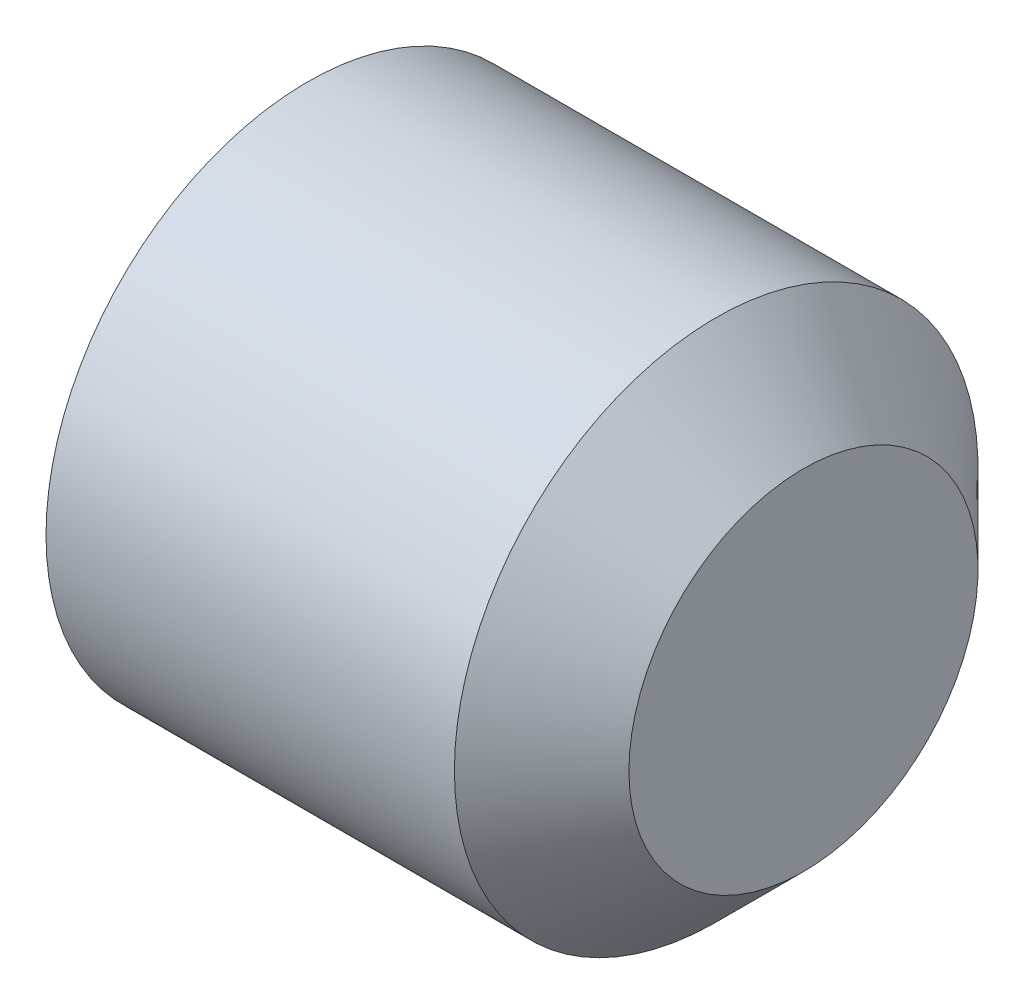
from build123d import *

# Parameters (mm, degrees)
CUT_EXTRUDE_1_DEPTH = 2
CHAMFER_1_SIZE      = 0.5545
CHAMFER_1_SIZE2     = 0.320140724


with BuildPart() as part:
    # Эскиз1 → Повернуть1 (revolve)
    with BuildSketch(Plane(origin=(0, 0, 0), x_dir=(-1, 0, 0), z_dir=(0, 0, -1))):
        Polygon((-6, 2), (-6, 0), (0, 0), (0, 3), (-5, 3), align=None)
    revolve(axis=Axis((6, 0, 0), (-1, 0, 0)))

    # Эскиз2 → Вырез-Вытянуть1 (cut)
    with BuildSketch(Plane.ZY):
        Polygon((1.732050808, 0), (0.866025404, 1.5), (-0.866025404, 1.5), (-1.732050808, 0), (-0.866025404, -1.5), (0.866025404, -1.5), align=None)
    extrude(amount=-CUT_EXTRUDE_1_DEPTH, mode=Mode.SUBTRACT)

    # Фаска1
    chamfer_1_edges = [part.edges().sort_by_distance(p)[0] for p in [
        (0, -3, 0),
    ]]
    chamfer_1_side = [part.faces().sort_by_distance(p)[0] for p in [
        (0, -2.915147186, 0),
    ]]
    chamfer(chamfer_1_edges, length=CHAMFER_1_SIZE, length2=CHAMFER_1_SIZE2, reference=chamfer_1_side[0])


solid = part.part
